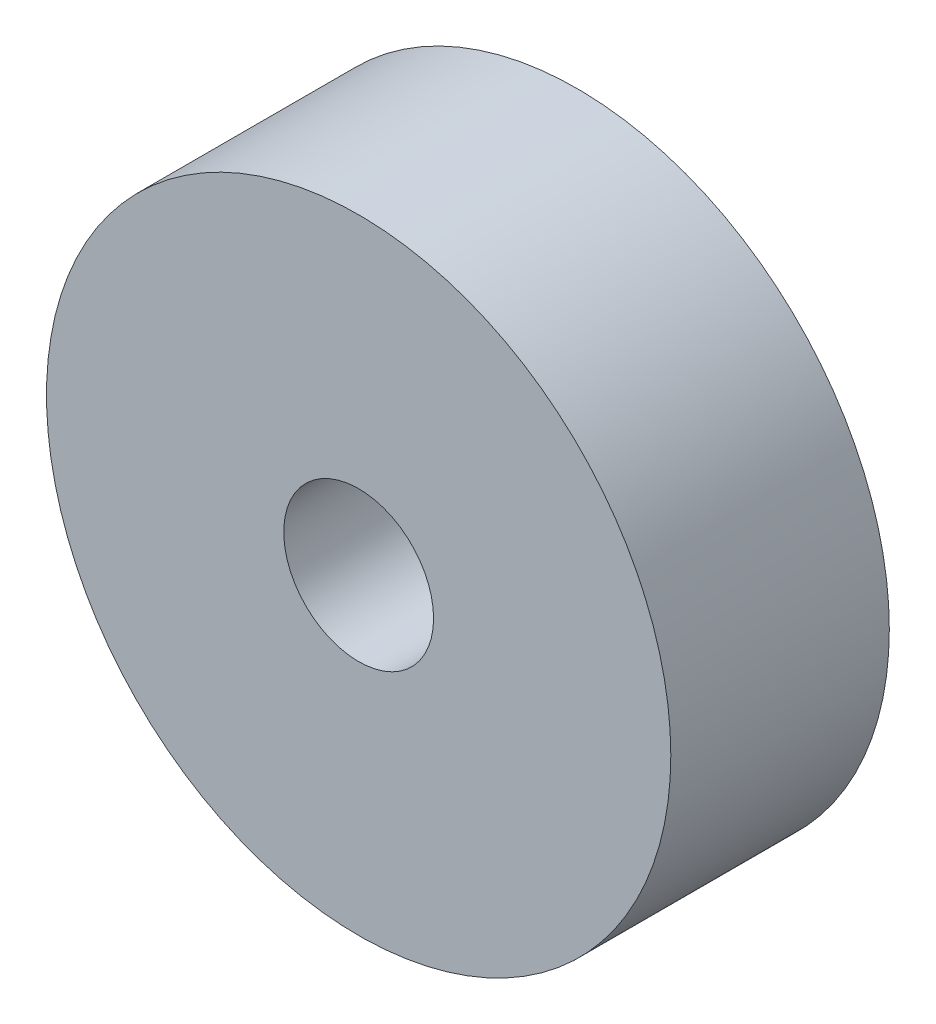
from build123d import *


with BuildPart() as part:
    # Sketch1 → Revolve1 (revolve)
    with BuildSketch(Plane(origin=(0, -7.80542761, 0), x_dir=(1, 0, 0), z_dir=(0, 1, 0))):
        with BuildLine():
            Line((7.58439152, 1.8), (7.58439152, 2.15))
            Line((7.58439152, 2.15), (7.38439152, 2.15))
            ThreePointArc((7.38439152, 2.15), (7.305162821, 2.112771868), (7.218560281, 2.1))
            Line((7.218560281, 2.1), (7.20439152, 2.1))
            Line((7.20439152, 2.1), (7.20439152, 1.8))
            Line((7.20439152, 1.8), (7.58439152, 1.8))
        make_face()
    revolve(axis=Axis((7.08439152, -7.80542761, -2.15), (0, 0, 1)))


solid = part.part
